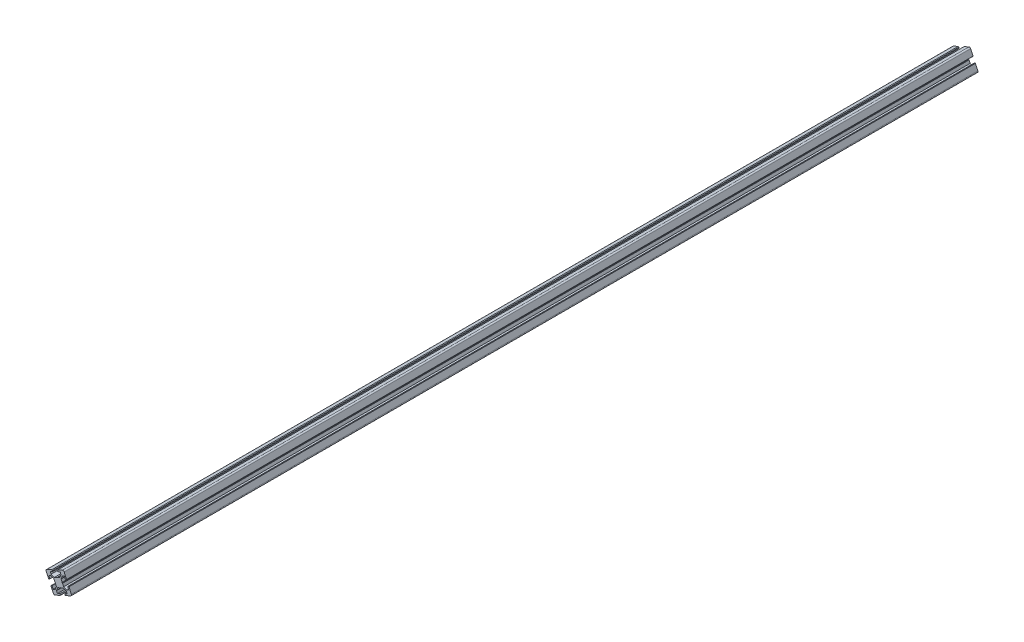
from build123d import *

# Parameters (mm, degrees)
BOSS_EXTRUDE1_DEPTH = 1916.03


with BuildPart() as part:
    # Sketch1 → Boss-Extrude1 (new body)
    with BuildSketch(Plane.XY):
        with BuildLine():
            Line((9.540560799, 11.143246319), (-0.920367578, 6.346418672))
            Line((-0.920367578, 6.346418672), (-1.535685442, 4.688896979))
            Line((-1.535685442, 4.688896979), (-0.889704709, 3.280141302))
            Line((-0.889704709, 3.280141302), (4.662851743, 5.826249577))
            Line((4.662851743, 5.826249577), (6.609420976, 1.581168696))
            Line((6.609420976, 1.581168696), (4.0846078, -5.220084546))
            Line((4.0846078, -5.220084546), (-1.08995176, -7.592863468))
            Line((-1.08995176, -7.592863468), (-1.576145343, -8.277856753))
            Line((-1.576145343, -8.277856753), (-2.41246372, -8.199297401))
            Line((-2.41246372, -8.199297401), (-7.58702328, -10.572076323))
            Line((-7.58702328, -10.572076323), (-14.388276522, -8.047263147))
            Line((-14.388276522, -8.047263147), (-16.334845756, -3.802182266))
            Line((-16.334845756, -3.802182266), (-10.782289304, -1.256073991))
            Line((-10.782289304, -1.256073991), (-11.428270037, 0.152681685))
            Line((-11.428270037, 0.152681685), (-13.08579173, 0.767999548))
            Line((-13.08579173, 0.767999548), (-23.546720108, -4.028828099))
            ThreePointArc((-23.546720108, -4.028828099), (-25.004600338, -5.599544785), (-24.924812915, -7.741086201))
            Line((-24.924812915, -7.741086201), (-19.848003398, -18.812599428))
            ThreePointArc((-19.848003398, -18.812599428), (-19.612395895, -19.031281462), (-19.291164682, -19.019313349))
            Line((-19.291164682, -19.019313349), (-17.127765546, -18.027293098))
            Line((-17.127765546, -18.027293098), (-19.607816172, -12.618795258))
            Line((-19.607816172, -12.618795258), (-15.362735291, -10.672226024))
            Line((-15.362735291, -10.672226024), (-8.561482049, -13.197039201))
            Line((-8.561482049, -13.197039201), (-6.188703127, -18.37159876))
            Line((-6.188703127, -18.37159876), (-5.503709842, -18.857792344))
            Line((-5.503709842, -18.857792344), (-5.582269194, -19.694110721))
            Line((-5.582269194, -19.694110721), (-3.209490272, -24.868670281))
            Line((-3.209490272, -24.868670281), (-5.734303449, -31.669923523))
            Line((-5.734303449, -31.669923523), (-9.97938433, -33.616492757))
            Line((-9.97938433, -33.616492757), (-12.459434956, -28.207994916))
            Line((-12.459434956, -28.207994916), (-14.622834092, -29.200015166))
            ThreePointArc((-14.622834092, -29.200015166), (-14.841516127, -29.435622669), (-14.829548013, -29.756853882))
            Line((-14.829548013, -29.756853882), (-9.752738496, -40.828367108))
            ThreePointArc((-9.752738496, -40.828367108), (-8.182021811, -42.286247338), (-6.040480394, -42.206459915))
            Line((-6.040480394, -42.206459915), (5.031032832, -37.129650398))
            ThreePointArc((5.031032832, -37.129650398), (5.249714867, -36.894042895), (5.237746753, -36.572811683))
            Line((5.237746753, -36.572811683), (4.245726503, -34.409412547))
            Line((4.245726503, -34.409412547), (-1.162771338, -36.889463173))
            Line((-1.162771338, -36.889463173), (-3.109340571, -32.644382292))
            Line((-3.109340571, -32.644382292), (-0.584527395, -25.84312905))
            Line((-0.584527395, -25.84312905), (4.590032165, -23.470350128))
            Line((4.590032165, -23.470350128), (5.076225748, -22.785356843))
            Line((5.076225748, -22.785356843), (5.912544125, -22.863916195))
            Line((5.912544125, -22.863916195), (11.087103685, -20.491137273))
            Line((11.087103685, -20.491137273), (17.888356928, -23.015950449))
            Line((17.888356928, -23.015950449), (19.834926161, -27.26103133))
            Line((19.834926161, -27.26103133), (14.426428321, -29.741081956))
            Line((14.426428321, -29.741081956), (15.418448571, -31.904481093))
            ThreePointArc((15.418448571, -31.904481093), (15.654056074, -32.123163127), (15.975287286, -32.111195014))
            Line((15.975287286, -32.111195014), (27.046800513, -27.034385497))
            ThreePointArc((27.046800513, -27.034385497), (28.504680743, -25.463668811), (28.42489332, -23.322127395))
            Line((28.42489332, -23.322127395), (23.348083803, -12.250614168))
            ThreePointArc((23.348083803, -12.250614168), (23.1124763, -12.031932134), (22.791245088, -12.043900247))
            Line((22.791245088, -12.043900247), (20.627845951, -13.035920498))
            Line((20.627845951, -13.035920498), (23.107896577, -18.444418338))
            Line((23.107896577, -18.444418338), (18.862815696, -20.390987572))
            Line((18.862815696, -20.390987572), (12.061562454, -17.866174395))
            Line((12.061562454, -17.866174395), (9.688783532, -12.691614835))
            Line((9.688783532, -12.691614835), (9.003790248, -12.205421252))
            Line((9.003790248, -12.205421252), (9.082349599, -11.369102875))
            Line((9.082349599, -11.369102875), (6.709570677, -6.194543315))
            Line((6.709570677, -6.194543315), (9.234383854, 0.606709927))
            Line((9.234383854, 0.606709927), (13.479464735, 2.553279161))
            Line((13.479464735, 2.553279161), (15.959515361, -2.85521868))
            Line((15.959515361, -2.85521868), (18.122914497, -1.863198429))
            ThreePointArc((18.122914497, -1.863198429), (18.341596532, -1.627590927), (18.329628418, -1.306359714))
            Line((18.329628418, -1.306359714), (13.252818901, 9.765153513))
            ThreePointArc((13.252818901, 9.765153513), (11.682102216, 11.223033742), (9.540560799, 11.143246319))
        make_face()
    extrude(amount=BOSS_EXTRUDE1_DEPTH)


solid = part.part
